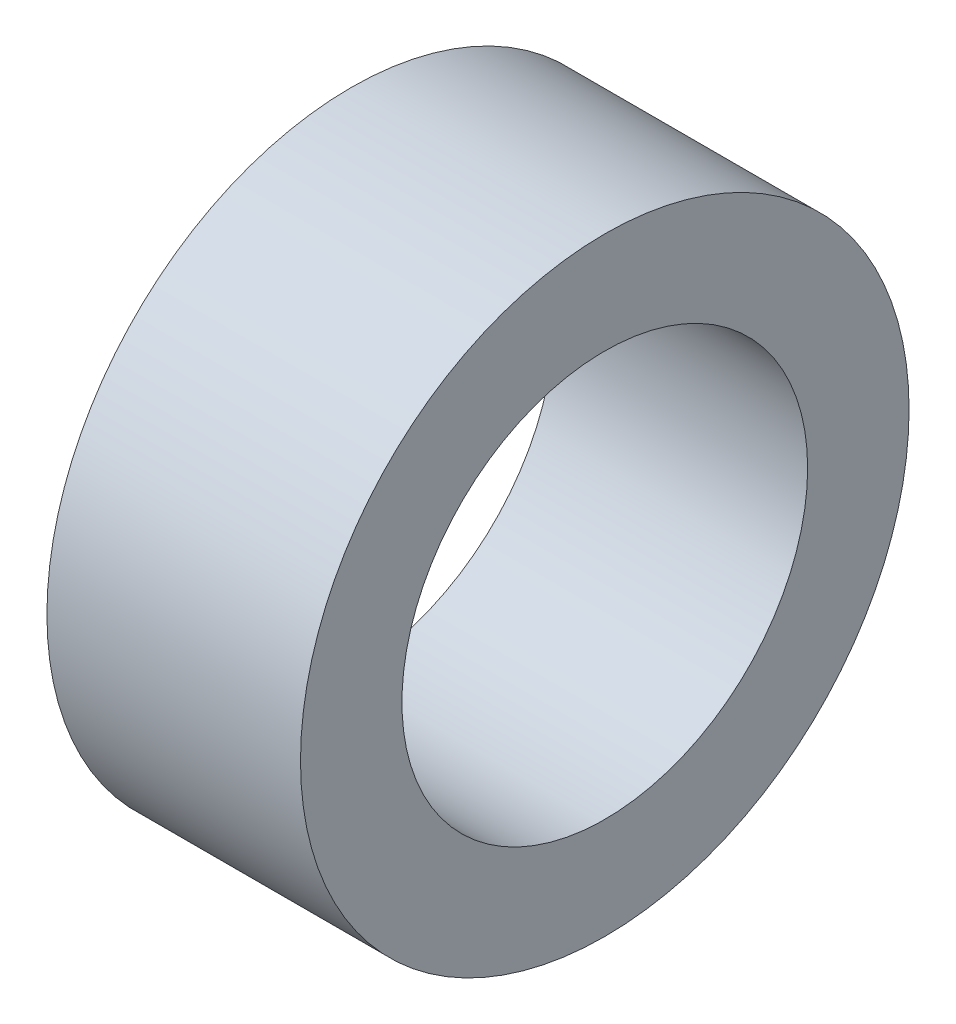
from build123d import *

# Parameters (mm, degrees)
SKETCH1_R           = 7.62
SKETCH1_R_2         = 5.08
BOSS_EXTRUDE1_DEPTH = 6.35


with BuildPart() as part:
    # Sketch1 → Boss-Extrude1 (new body)
    with BuildSketch(Plane(origin=(0, 0, 0), x_dir=(0, 0, -1), z_dir=(1, 0, 0))):
        Circle(SKETCH1_R)
        Circle(SKETCH1_R_2, mode=Mode.SUBTRACT)
    extrude(amount=BOSS_EXTRUDE1_DEPTH)


solid = part.part
